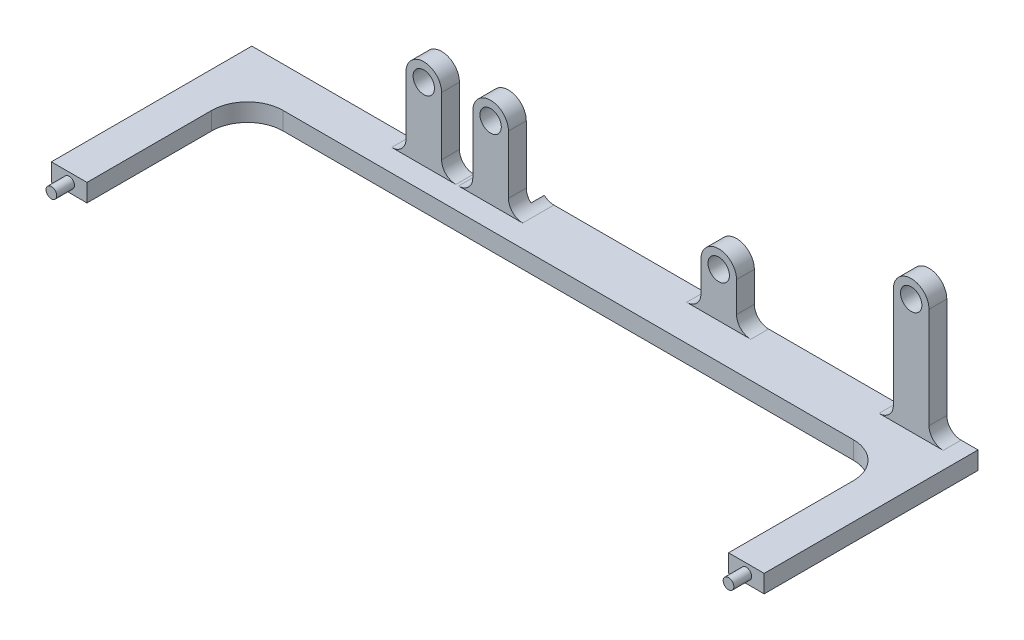
from build123d import *

# Parameters (mm, degrees)
BOSS_EXTRUDE1_DEPTH     = 40
SKETCH2_R               = 24
BOSS_EXTRUDE2_DEPTH     = 40
SKETCH3_R               = 24
BOSS_EXTRUDE3_DEPTH     = 40
SCALE1_SCALE            = 0.125
FILLET3_R               = 4
FILLET4_R               = 4
CUT_EXTRUDE1_DEPTH      = 38.275
CUT_EXTRUDE1_DEPTH_BACK = 6
CUT_EXTRUDE2_DEPTH      = 38.275
CUT_EXTRUDE2_DEPTH_BACK = 6
SKETCH6_R               = 1.5
BOSS_EXTRUDE4_DEPTH     = 5


with BuildPart() as part:
    # Sketch1 → Boss-Extrude1 (new body)
    with BuildSketch(Plane(origin=(0, 0, 0), x_dir=(1, 0, 0), z_dir=(0, 1, 0))):
        Polygon((-173.422280891, 480), (-173.422280891, 450), (-800, 450), (-800, -450), (-173.422280891, -450), (-173.422280891, -480), (800, -480), (800, 480), align=None)
    extrude(amount=-BOSS_EXTRUDE1_DEPTH)

    # Sketch2 → Boss-Extrude2 (add)
    with BuildSketch(Plane.XY.offset(480)):
        with BuildLine():
            Line((218, 0), (298, 0))
            Line((298, 0), (298, 100))
            ThreePointArc((298, 100), (258, 140), (218, 100))
            Line((218, 100), (218, 0))
        make_face()
        with Locations((258, 100)):
            Circle(SKETCH2_R, mode=Mode.SUBTRACT)
        with BuildLine():
            Line((650, 258.2), (650, 0))
            Line((650, 0), (730, 0))
            Line((730, 0), (730, 258.2))
            ThreePointArc((730, 258.2), (690, 298.2), (650, 258.2))
        make_face()
        with Locations((690, 258.2)):
            Circle(SKETCH2_R, mode=Mode.SUBTRACT)
        Polygon((650, 0), (298, 0), (218, 0), (-173.422280891, 0), (-173.422280891, -40), (800, -40), (800, 0), (730, 0), align=None)
    extrude(amount=-BOSS_EXTRUDE2_DEPTH)

    # Mirror1: part across plane


with BuildPart() as part_1:
    add(part.part)
    add(part.part.mirror(Plane.XY))

    # Sketch3 → Boss-Extrude3 (add)
    with BuildSketch(Plane.XY.offset(450)):
        with BuildLine():
            Line((-414, 0), (-334, 0))
            Line((-334, 0), (-334, 162.7))
            ThreePointArc((-334, 162.7), (-374, 202.7), (-414, 162.7))
            Line((-414, 162.7), (-414, 0))
        make_face()
        with Locations((-374, 162.7)):
            Circle(SKETCH3_R, mode=Mode.SUBTRACT)
        with BuildLine():
            Line((-264, 0), (-184, 0))
            Line((-184, 0), (-184, 162.7))
            ThreePointArc((-184, 162.7), (-224, 202.7), (-264, 162.7))
            Line((-264, 162.7), (-264, 0))
        make_face()
        with Locations((-224, 162.7)):
            Circle(SKETCH3_R, mode=Mode.SUBTRACT)
    boss_extrude3 = extrude(amount=-BOSS_EXTRUDE3_DEPTH)

    # Mirror2: Boss-Extrude3 across plane
    add(boss_extrude3.mirror(Plane.XY))


with BuildPart() as part_2:
    # Scale1: scaled about (22.22402446, -11.339866564, 0)
    add(part_1.part.scale(SCALE1_SCALE).moved(Location((19.446021402, -9.922383243, 0))))

    # Fillet3
    fillet3_edges = [part_2.edges().sort_by_distance(p)[0] for p in [
        (-32.303978598, -9.922383243, 53.75),
        (-13.553978598, -9.922383243, 53.75),
        (-32.303978598, -9.922383243, -53.75),
        (-13.553978598, -9.922383243, -53.75),
        (46.696021403, -9.922383243, 57.5),
        (100.696021403, -9.922383243, 57.5),
        (100.696021403, -9.922383243, -57.5),
        (46.696021403, -9.922383243, -57.5),
    ]]
    fillet(fillet3_edges, radius=FILLET3_R)

    # Fillet4
    fillet4_edges = [part_2.edges().sort_by_distance(p)[0] for p in [
        (-3.553978598, -9.922383243, -53.75),
        (-22.303978598, -9.922383243, -53.75),
        (56.696021403, -9.922383243, -57.5),
        (110.696021402, -9.922383243, -57.5),
        (110.696021402, -9.922383243, 57.5),
        (56.696021403, -9.922383243, 57.5),
        (-3.553978598, -9.922383243, 53.75),
        (-22.303978598, -9.922383243, 53.75),
    ]]
    fillet(fillet4_edges, radius=FILLET4_R)

    # Sketch4 → Cut-Extrude1 (cut, two sides)
    with BuildSketch(Plane(origin=(0, -9.922383244, 0), x_dir=(1, 0, 0), z_dir=(0, 1, 0))) as cut_extrude1_sk:
        with BuildLine():
            Line((-60.553978598, 45), (99.446021402, 45))
            ThreePointArc((99.446021402, 45), (106.517089214, 42.071067812), (109.446021402, 35))
            Line((109.446021402, 35), (109.446021402, -35))
            ThreePointArc((109.446021402, -35), (106.517089214, -42.071067812), (99.446021402, -45))
            Line((99.446021402, -45), (-60.553978598, -45))
            ThreePointArc((-60.553978598, -45), (-67.62504641, -42.071067812), (-70.553978598, -35))
            Line((-70.553978598, -35), (-70.553978598, 35))
            ThreePointArc((-70.553978598, 35), (-67.62504641, 42.071067812), (-60.553978598, 45))
        make_face()
    extrude(amount=CUT_EXTRUDE1_DEPTH, mode=Mode.SUBTRACT)
    extrude(cut_extrude1_sk.sketch, amount=-CUT_EXTRUDE1_DEPTH_BACK, mode=Mode.SUBTRACT)

    # Sketch5 → Cut-Extrude2 (cut, two sides)
    with BuildSketch(Plane(origin=(0, -9.922383244, 0), x_dir=(1, 0, 0), z_dir=(0, 1, 0))) as cut_extrude2_sk:
        Polygon((0, 0), (123.509842575, 0), (123.509842575, -66.212941814), (-94.641009198, -66.212941814), (-94.641009198, 0), align=None)
    extrude(amount=CUT_EXTRUDE2_DEPTH, mode=Mode.SUBTRACT)
    extrude(cut_extrude2_sk.sketch, amount=-CUT_EXTRUDE2_DEPTH_BACK, mode=Mode.SUBTRACT)

    # Sketch6 → Boss-Extrude4 (add)
    with BuildSketch(Plane.XY):
        with Locations((-75.553978598, -12.422383244)):
            Circle(SKETCH6_R)
        with Locations((114.446021402, -12.422383244)):
            Circle(SKETCH6_R)
    extrude(amount=BOSS_EXTRUDE4_DEPTH)


solid = part_2.part
